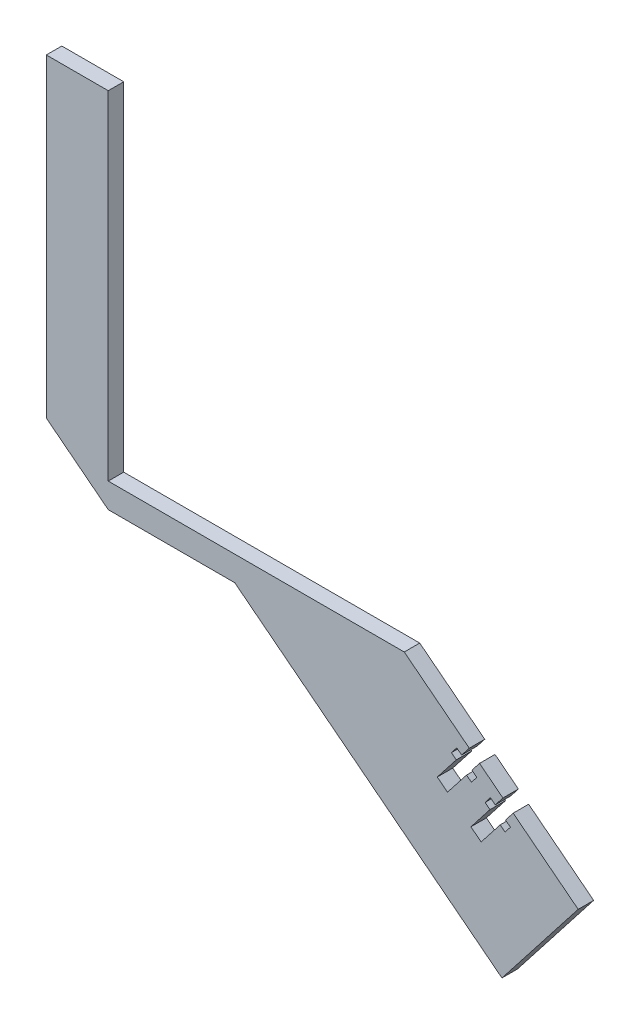
from build123d import *

# Parameters (mm, degrees)
BOSS_EXTRUDE1_DEPTH     = 5
CUT_EXTRUDE1_DEPTH      = 1
CUT_EXTRUDE1_DEPTH_BACK = 6


with BuildPart() as part:
    # Sketch3 → Boss-Extrude1 (new body)
    with BuildSketch(Plane.XY.offset(-218)):
        Polygon((-331.826668729, 452.47886283), (-275.647209147, 408.586658554), (-300.273668161, 377.066228409), (-386.557905491, 444.47886283), (-427.432442284, 444.47886283), (-447.432442284, 460.10457536), (-447.432442284, 561.679955314), (-427.432442284, 561.679955314), (-427.432442284, 452.47886283), align=None)
    extrude(amount=-BOSS_EXTRUDE1_DEPTH)

    # Sketch4 → Cut-Extrude1 (cut, two sides)
    with BuildSketch(Plane(origin=(0, 0, -223), x_dir=(-1, 0, 0), z_dir=(0, 0, -1))) as cut_extrude1_sk:
        Polygon((296.647620515, 424.993978106), (299.95726568, 427.579756302), (302.419911581, 424.427713288), (303.995933089, 425.659036238), (305.71978522, 423.452606128), (304.143763712, 422.221283178), (310.300378466, 414.341175642), (306.990733301, 411.755397445), (300.834118547, 419.635504981), (299.25809704, 418.404182031), (297.534244909, 420.610612141), (299.110266416, 421.841935091), align=None)
        Polygon((309.979258098, 430.333722067), (308.40323659, 429.102399116), (310.127088721, 426.895969006), (311.703110229, 428.127291957), (317.859724982, 420.24718442), (321.169370147, 422.832962617), (315.012755394, 430.713070153), (316.588776901, 431.944393104), (314.86492477, 434.150823214), (313.288903263, 432.919500263), (310.826257361, 436.071543277), (307.516612196, 433.485765081), align=None)
    extrude(amount=CUT_EXTRUDE1_DEPTH, mode=Mode.SUBTRACT)
    extrude(cut_extrude1_sk.sketch, amount=-CUT_EXTRUDE1_DEPTH_BACK, mode=Mode.SUBTRACT)


solid = part.part
